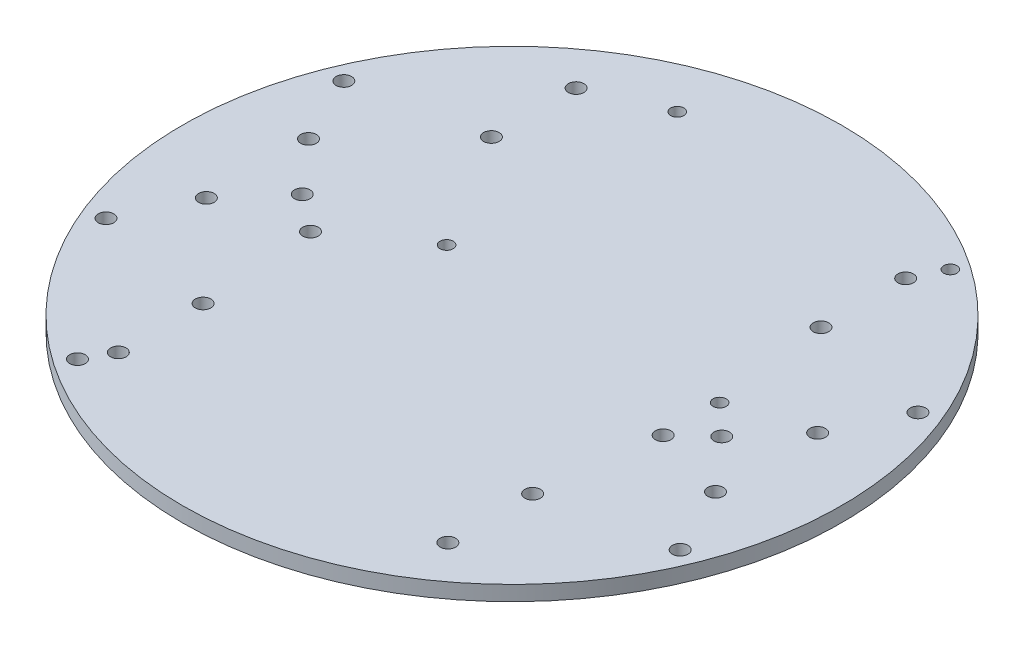
from build123d import *

# Parameters (mm, degrees)
BASE_W_MOTOR_MOUNTS_R     = 70
BASE_W_MOTOR_MOUNTS_R_2   = 1.651
BOSS_EXTRUDE1_DEPTH       = 3.175
STANDOFFS_TOP_BOTTOM_R    = 1.65
CUT_EXTRUDE2_DEPTH        = 3.175
PI_AND_MEGA_STANDOFFS_R   = 1.4
PI_AND_MEGA_STANDOFFS_R_2 = 1.65
CUT_EXTRUDE3_DEPTH        = 3.175


with BuildPart() as part:
    # Base w/ Motor Mounts → Boss-Extrude1 (new body)
    with BuildSketch(Plane(origin=(0, 0, 0), x_dir=(1, 0, 0), z_dir=(0, 1, 0))):
        Circle(BASE_W_MOTOR_MOUNTS_R)
        with Locations((44.55, 0)):
            Circle(BASE_W_MOTOR_MOUNTS_R_2, mode=Mode.SUBTRACT)
        with Locations((54.075, 10.85)):
            Circle(BASE_W_MOTOR_MOUNTS_R_2, mode=Mode.SUBTRACT)
        with Locations((54.075, -10.85)):
            Circle(BASE_W_MOTOR_MOUNTS_R_2, mode=Mode.SUBTRACT)
        with Locations((-54.075, -10.85)):
            Circle(BASE_W_MOTOR_MOUNTS_R_2, mode=Mode.SUBTRACT)
        with Locations((-54.075, 10.85)):
            Circle(BASE_W_MOTOR_MOUNTS_R_2, mode=Mode.SUBTRACT)
        with Locations((-44.55, 0)):
            Circle(BASE_W_MOTOR_MOUNTS_R_2, mode=Mode.SUBTRACT)
    extrude(amount=BOSS_EXTRUDE1_DEPTH)

    # Standoffs (top / bottom) → Cut-Extrude2 (cut)
    with BuildSketch(Plane(origin=(0, 0, 0), x_dir=(1, 0, 0), z_dir=(0, 1, 0))):
        with Locations((60.976049146, 25.257106536)):
            Circle(STANDOFFS_TOP_BOTTOM_R)
        with Locations((60.976049146, -25.257106536)):
            Circle(STANDOFFS_TOP_BOTTOM_R)
        with Locations((-60.976049146, -25.257106536)):
            Circle(STANDOFFS_TOP_BOTTOM_R)
        with Locations((-60.976049146, 25.257106536)):
            Circle(STANDOFFS_TOP_BOTTOM_R)
        with Locations((35, 48.621778265)):
            Circle(STANDOFFS_TOP_BOTTOM_R)
        with Locations((35, 30.621778265)):
            Circle(STANDOFFS_TOP_BOTTOM_R)
        with Locations((35, -30.621778265)):
            Circle(STANDOFFS_TOP_BOTTOM_R)
        with Locations((35, -48.621778265)):
            Circle(STANDOFFS_TOP_BOTTOM_R)
        with Locations((-35, -48.621778265)):
            Circle(STANDOFFS_TOP_BOTTOM_R)
        with Locations((-35, -30.621778265)):
            Circle(STANDOFFS_TOP_BOTTOM_R)
        with Locations((-35, 30.621778265)):
            Circle(STANDOFFS_TOP_BOTTOM_R)
        with Locations((-35, 48.621778265)):
            Circle(STANDOFFS_TOP_BOTTOM_R)
    extrude(amount=CUT_EXTRUDE2_DEPTH, mode=Mode.SUBTRACT)

    # Pi and Mega Standoffs → Cut-Extrude3 (cut)
    with BuildSketch(Plane(origin=(0, 0, 0), x_dir=(1, 0, 0), z_dir=(0, 1, 0))):
        with Locations((-19.9, 55)):
            Circle(PI_AND_MEGA_STANDOFFS_R)
        with Locations((38.1, 55)):
            Circle(PI_AND_MEGA_STANDOFFS_R)
        with Locations((38.1, 6)):
            Circle(PI_AND_MEGA_STANDOFFS_R)
        with Locations((-19.9, 6)):
            Circle(PI_AND_MEGA_STANDOFFS_R)
        with Locations((-38.1, -54.2)):
            Circle(PI_AND_MEGA_STANDOFFS_R_2)
        with Locations((-36.8, -6)):
            Circle(PI_AND_MEGA_STANDOFFS_R_2)
        with Locations((38.1, -6)):
            Circle(PI_AND_MEGA_STANDOFFS_R_2)
    extrude(amount=CUT_EXTRUDE3_DEPTH, mode=Mode.SUBTRACT)


solid = part.part
